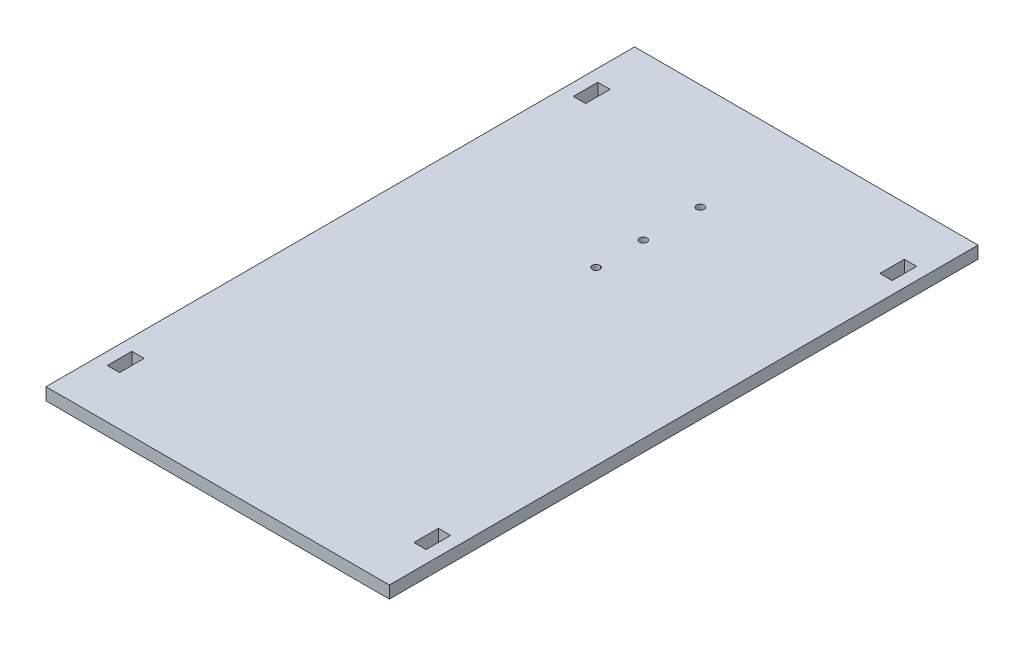
from build123d import *

# Parameters (mm, degrees)
SKETCH1_W           = 177.8
SKETCH1_H           = 304.8
SKETCH1_R           = 1.93499994
SKETCH1_W_2         = 6.35
SKETCH1_H_2         = 12.7
BOSS_EXTRUDE1_DEPTH = 6.35


with BuildPart() as part:
    # Sketch1 → Boss-Extrude1 (new body)
    with BuildSketch(Plane(origin=(0, 0, 0), x_dir=(1, 0, 0), z_dir=(0, 1, 0))):
        with Locations((88.9, 152.4)):
            Rectangle(SKETCH1_W, SKETCH1_H)
        with Locations((88.9, 249.900000072)):
            Circle(SKETCH1_R, mode=Mode.SUBTRACT)
        with Locations((88.9, 220.400000144)):
            Circle(SKETCH1_R, mode=Mode.SUBTRACT)
        with Locations((88.9, 195.900000122)):
            Circle(SKETCH1_R, mode=Mode.SUBTRACT)
        with Locations((168.275, 273.05)):
            Rectangle(SKETCH1_W_2, SKETCH1_H_2, mode=Mode.SUBTRACT)
        with Locations((9.525, 273.05)):
            Rectangle(SKETCH1_W_2, SKETCH1_H_2, mode=Mode.SUBTRACT)
        with Locations((9.525, 31.75)):
            Rectangle(SKETCH1_W_2, SKETCH1_H_2, mode=Mode.SUBTRACT)
        with Locations((168.275, 31.75)):
            Rectangle(SKETCH1_W_2, SKETCH1_H_2, mode=Mode.SUBTRACT)
    extrude(amount=BOSS_EXTRUDE1_DEPTH)


solid = part.part
